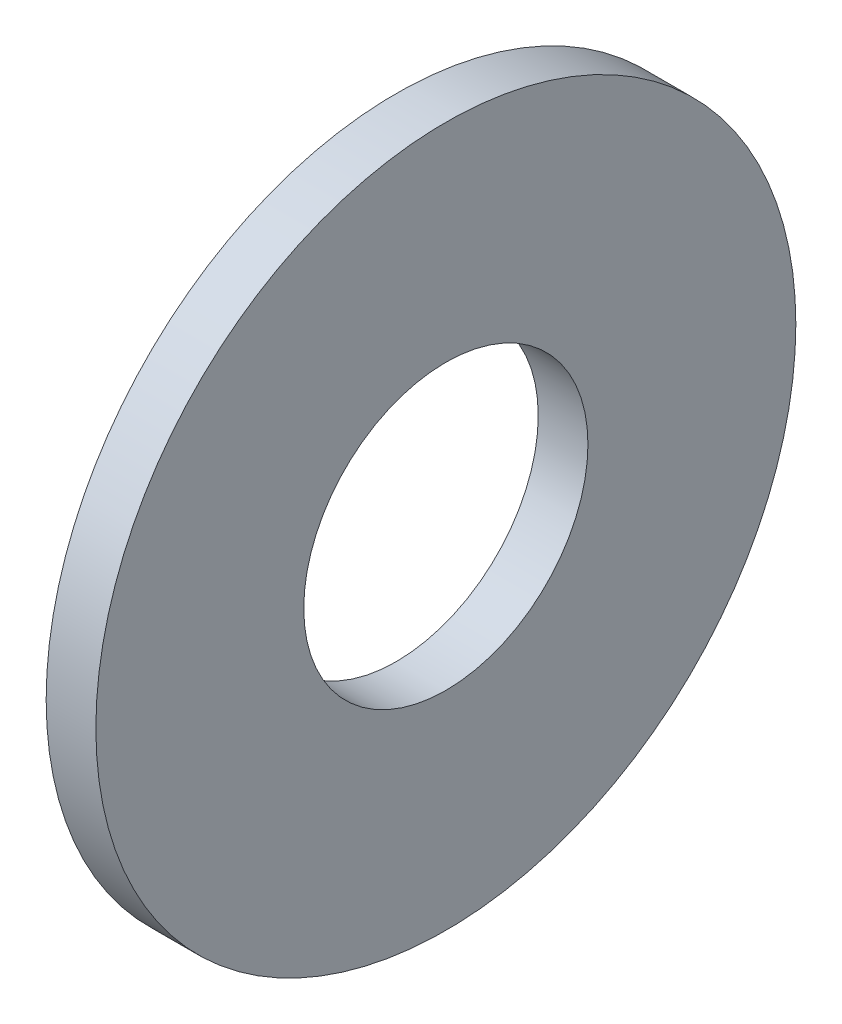
from build123d import *

# Parameters (mm, degrees)
SKETCH1_R           = 12.7
SKETCH1_R_2         = 5.1562
BOSS_EXTRUDE1_DEPTH = 1.8034


with BuildPart() as part:
    # Sketch1 → Boss-Extrude1 (new body)
    with BuildSketch(Plane(origin=(0, 0, 0), x_dir=(0, 0, -1), z_dir=(1, 0, 0))):
        Circle(SKETCH1_R)
        Circle(SKETCH1_R_2, mode=Mode.SUBTRACT)
    extrude(amount=BOSS_EXTRUDE1_DEPTH)


solid = part.part
